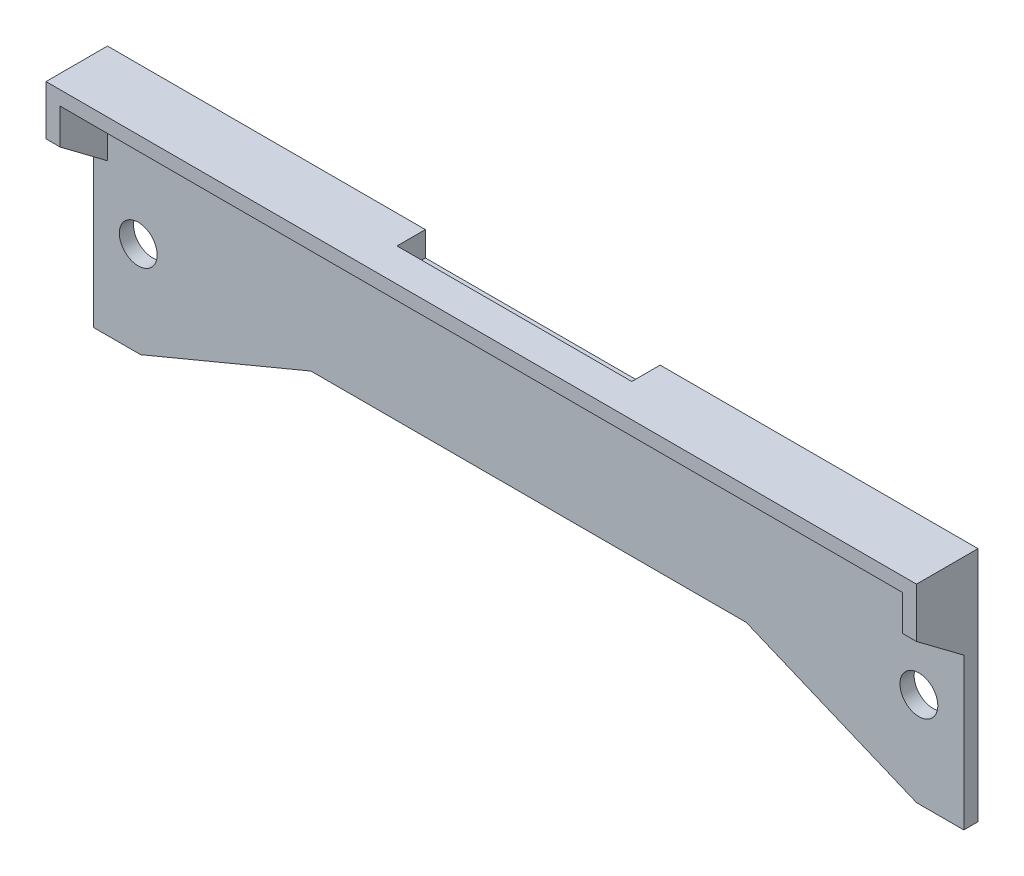
from build123d import *

# Parameters (mm, degrees)
SKETCH1_W           = 184
SKETCH1_H           = 50
SKETCH1_R           = 4
BOSS_EXTRUDE2_DEPTH = 3
SKETCH2_W           = 184
SKETCH2_H           = 3
BOSS_EXTRUDE3_DEPTH = 20
BOSS_EXTRUDE4_DEPTH = 3
BOSS_EXTRUDE5_DEPTH = 3
SKETCH5_W           = 49.622419658
SKETCH5_H           = 10.386730574
CUT_EXTRUDE3_DEPTH  = 6
SKETCH7_W           = 184
SKETCH7_H           = 10
CUT_EXTRUDE5_DEPTH  = 16
CUT_EXTRUDE7_DEPTH  = 16


with BuildPart() as part:
    # Sketch1 → Boss-Extrude2 (new body)
    with BuildSketch(Plane.XY):
        with Locations((92, 25)):
            Rectangle(SKETCH1_W, SKETCH1_H)
        with Locations((9.5, 20)):
            Circle(SKETCH1_R, mode=Mode.SUBTRACT)
        with Locations((174.5, 20)):
            Circle(SKETCH1_R, mode=Mode.SUBTRACT)
    extrude(amount=BOSS_EXTRUDE2_DEPTH)

    # Sketch2 → Boss-Extrude3 (add)
    with BuildSketch(Plane.XY.offset(3)):
        with Locations((92, 48.5)):
            Rectangle(SKETCH2_W, SKETCH2_H)
    extrude(amount=BOSS_EXTRUDE3_DEPTH)

    # Sketch3 → Boss-Extrude4 (add)
    with BuildSketch(Plane.ZY):
        Polygon((23, 47), (3, 47), (3, 32), align=None)
    extrude(amount=-BOSS_EXTRUDE4_DEPTH)

    # Sketch4 → Boss-Extrude5 (add)
    with BuildSketch(Plane(origin=(184, 0, 0), x_dir=(0, 0, -1), z_dir=(1, 0, 0))):
        Polygon((-23, 47), (-3, 32), (-3, 47), align=None)
    extrude(amount=-BOSS_EXTRUDE5_DEPTH)

    # Sketch5 → Cut-Extrude3 (cut)
    with BuildSketch(Plane(origin=(0, 0, 0), x_dir=(-1, 0, 0), z_dir=(0, 0, -1))):
        with Locations((-92, 50)):
            Rectangle(SKETCH5_W, SKETCH5_H)
    extrude(amount=-CUT_EXTRUDE3_DEPTH, mode=Mode.SUBTRACT)

    # Sketch7 → Cut-Extrude5 (cut)
    with BuildSketch(Plane(origin=(0, 50, 0), x_dir=(1, 0, 0), z_dir=(0, 1, 0))):
        with Locations((92, -18)):
            Rectangle(SKETCH7_W, SKETCH7_H)
    extrude(amount=-CUT_EXTRUDE5_DEPTH, mode=Mode.SUBTRACT)

    # Sketch8 → Cut-Extrude7 (cut)
    with BuildSketch(Plane.XY.offset(3)):
        Polygon((46, 15), (10, 0), (174, 0), (138, 15), align=None)
    extrude(amount=-CUT_EXTRUDE7_DEPTH, mode=Mode.SUBTRACT)


solid = part.part
